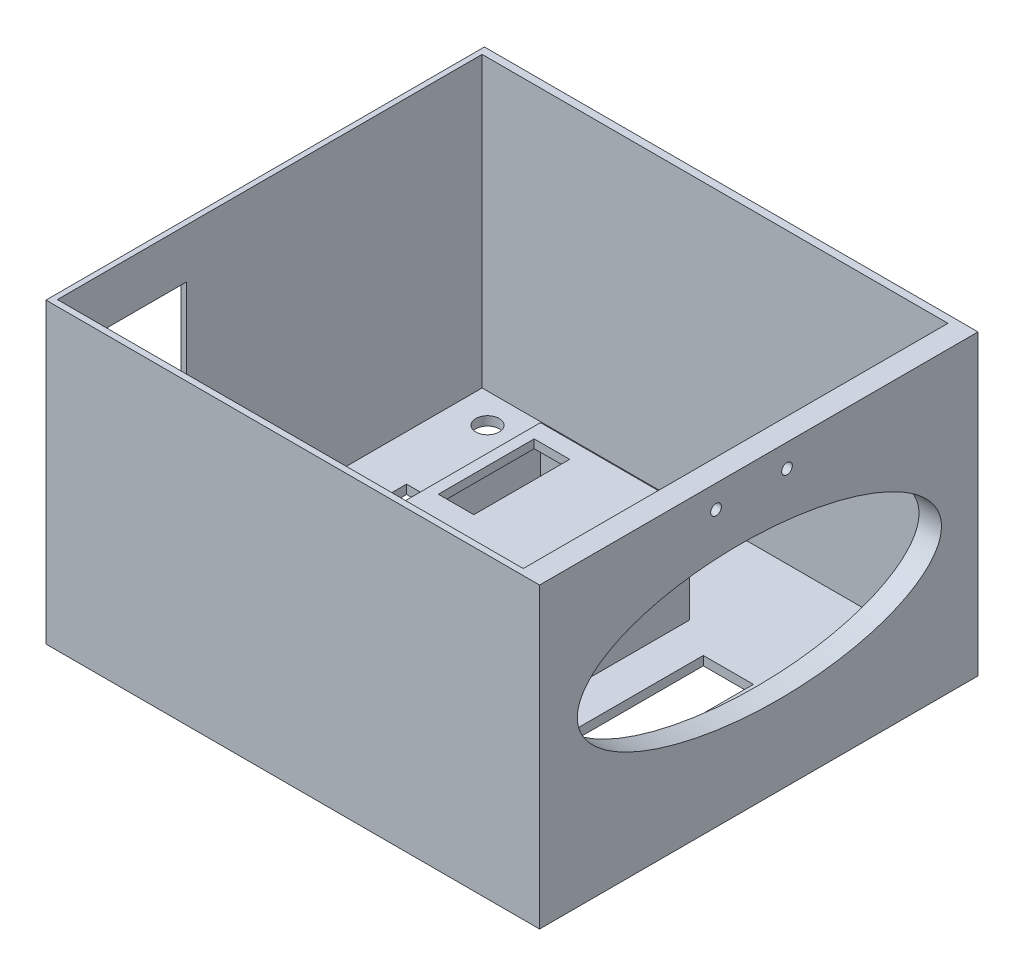
from build123d import *

# Parameters (mm, degrees)
SKETCH1_W           = 164
SKETCH1_H           = 145.68
BOSS_EXTRUDE1_DEPTH = 3
SKETCH2_W           = 164
SKETCH2_H           = 145.68
SKETCH2_W_2         = 154.794377853
SKETCH2_H_2         = 141.122884214
BOSS_EXTRUDE2_DEPTH = 96
SKETCH4_RX          = 60.571165747
SKETCH4_RY          = 25.38547853
CUT_EXTRUDE1_DEPTH  = 20
SKETCH6_W           = 39.790164022
SKETCH6_H           = 75.651590962
CUT_EXTRUDE3_DEPTH  = 20
SKETCH8_W           = 49.5692413
SKETCH8_H           = 91.849069086
BOSS_EXTRUDE3_DEPTH = 32
SKETCH7_W           = 45
SKETCH7_H           = 87.31
CUT_EXTRUDE4_DEPTH  = 32.17
SKETCH9_W           = 11.79717637
SKETCH9_H           = 31.86635219
CUT_EXTRUDE5_DEPTH  = 40
SKETCH11_W          = 16.650134538
SKETCH11_H          = 74.314635754
SKETCH11_W_2        = 24.505886262
CUT_EXTRUDE7_DEPTH  = 40
SKETCH12_R          = 1.77
SKETCH12_R_2        = 1.774021332
CUT_EXTRUDE8_DEPTH  = 40
SKETCH13_R          = 3.893526171
CUT_EXTRUDE9_DEPTH  = 40


with BuildPart() as part:
    # Sketch1 → Boss-Extrude1 (new body)
    with BuildSketch(Plane(origin=(0, 0, 0), x_dir=(1, 0, 0), z_dir=(0, 1, 0))):
        with Locations((9.099573667, 28.508659662)):
            Rectangle(SKETCH1_W, SKETCH1_H)
    extrude(amount=BOSS_EXTRUDE1_DEPTH)

    # Sketch2 → Boss-Extrude2 (add)
    with BuildSketch(Plane(origin=(0, 3, 0), x_dir=(1, 0, 0), z_dir=(0, 1, 0))):
        with Locations((9.099573667, 28.508659662)):
            Rectangle(SKETCH2_W, SKETCH2_H)
        with Locations((6.2438887, 28.265919971)):
            Rectangle(SKETCH2_W_2, SKETCH2_H_2, mode=Mode.SUBTRACT)
    extrude(amount=BOSS_EXTRUDE2_DEPTH)

    # Sketch4 → Cut-Extrude1 (cut)
    with BuildSketch(Plane(origin=(91.099573667, 0, 0), x_dir=(0, 0, -1), z_dir=(1, 0, 0))):
        with Locations(Location((28.714709394, 51.858345631), (0, 0, -3.107007487))):
            Ellipse(SKETCH4_RX, SKETCH4_RY)
    extrude(amount=-CUT_EXTRUDE1_DEPTH, mode=Mode.SUBTRACT)

    # Sketch6 → Cut-Extrude3 (cut)
    with BuildSketch(Plane.ZY.offset(72.900426333)):
        with Locations((19.353212204, 44.793227562)):
            Rectangle(SKETCH6_W, SKETCH6_H)
    extrude(amount=-CUT_EXTRUDE3_DEPTH, mode=Mode.SUBTRACT)

    # Sketch8 → Boss-Extrude3 (add)
    with BuildSketch(Plane(origin=(0, 3, 0), x_dir=(1, 0, 0), z_dir=(0, 1, 0))):
        with Locations((5.315093732, 20.62475692)):
            Rectangle(SKETCH8_W, SKETCH8_H)
    extrude(amount=BOSS_EXTRUDE3_DEPTH)

    # Sketch7 → Cut-Extrude4 (cut)
    with BuildSketch(Plane.XZ):
        with Locations((5.233997278, -20.691377503)):
            Rectangle(SKETCH7_W, SKETCH7_H)
    extrude(amount=-CUT_EXTRUDE4_DEPTH, mode=Mode.SUBTRACT)

    # Sketch9 → Cut-Extrude5 (cut)
    with BuildSketch(Plane.XZ.offset(-32.17)):
        with Locations((-9.959298471, -44.905011983)):
            Rectangle(SKETCH9_W, SKETCH9_H)
    extrude(amount=-CUT_EXTRUDE5_DEPTH, mode=Mode.SUBTRACT)

    # Sketch11 → Cut-Extrude7 (cut)
    with BuildSketch(Plane.XZ):
        with Locations((50.891184892, -21.453909531)):
            Rectangle(SKETCH11_W, SKETCH11_H)
        with Locations((-43.781754887, -21.453909531)):
            Rectangle(SKETCH11_W_2, SKETCH11_H)
    extrude(amount=-CUT_EXTRUDE7_DEPTH, mode=Mode.SUBTRACT)

    # Sketch12 → Cut-Extrude8 (cut)
    with BuildSketch(Plane(origin=(91.099573667, 0, 0), x_dir=(0, 0, -1), z_dir=(1, 0, 0))):
        with Locations((37.87743885, 91.391738709)):
            Circle(SKETCH12_R)
        with Locations((14.300129623, 91.391738709)):
            Circle(SKETCH12_R_2)
    extrude(amount=-CUT_EXTRUDE8_DEPTH, mode=Mode.SUBTRACT)

    # Sketch13 → Cut-Extrude9 (cut)
    with BuildSketch(Plane.XZ):
        with Locations((-59.534784008, -89.003983448)):
            Circle(SKETCH13_R)
    extrude(amount=-CUT_EXTRUDE9_DEPTH, mode=Mode.SUBTRACT)


solid = part.part
